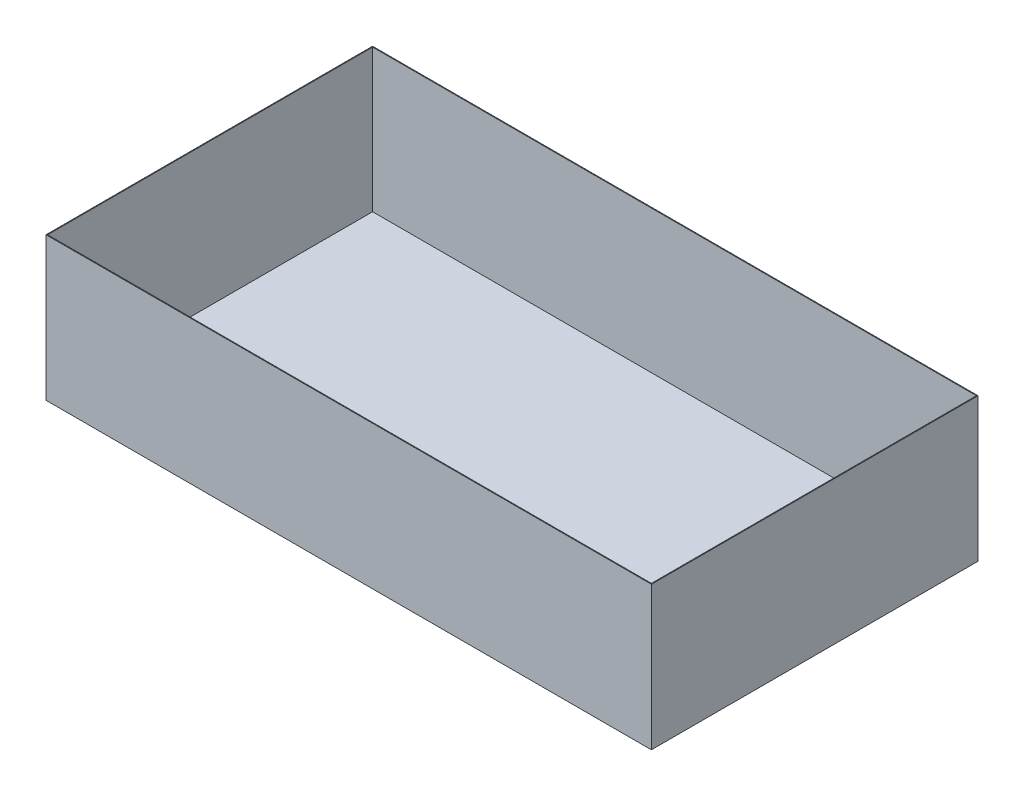
from build123d import *

# Parameters (mm, degrees)
SKETCH1_W           = 760
SKETCH1_H           = 410
BOSS_EXTRUDE1_DEPTH = 180
SHELL2_T            = -1


with BuildPart() as part:
    # Sketch1 → Boss-Extrude1 (new body)
    with BuildSketch(Plane(origin=(0, 0, 0), x_dir=(1, 0, 0), z_dir=(0, 1, 0))):
        with Locations((155.023847377, -114.419713831)):
            Rectangle(SKETCH1_W, SKETCH1_H)
    extrude(amount=BOSS_EXTRUDE1_DEPTH)

    # Shell2
    shell2_openings = [part.faces().sort_by_distance(p)[0] for p in [
        (155.023847377, 180, 114.419713831),
    ]]
    offset(amount=SHELL2_T, openings=shell2_openings, kind=Kind.INTERSECTION)


solid = part.part
